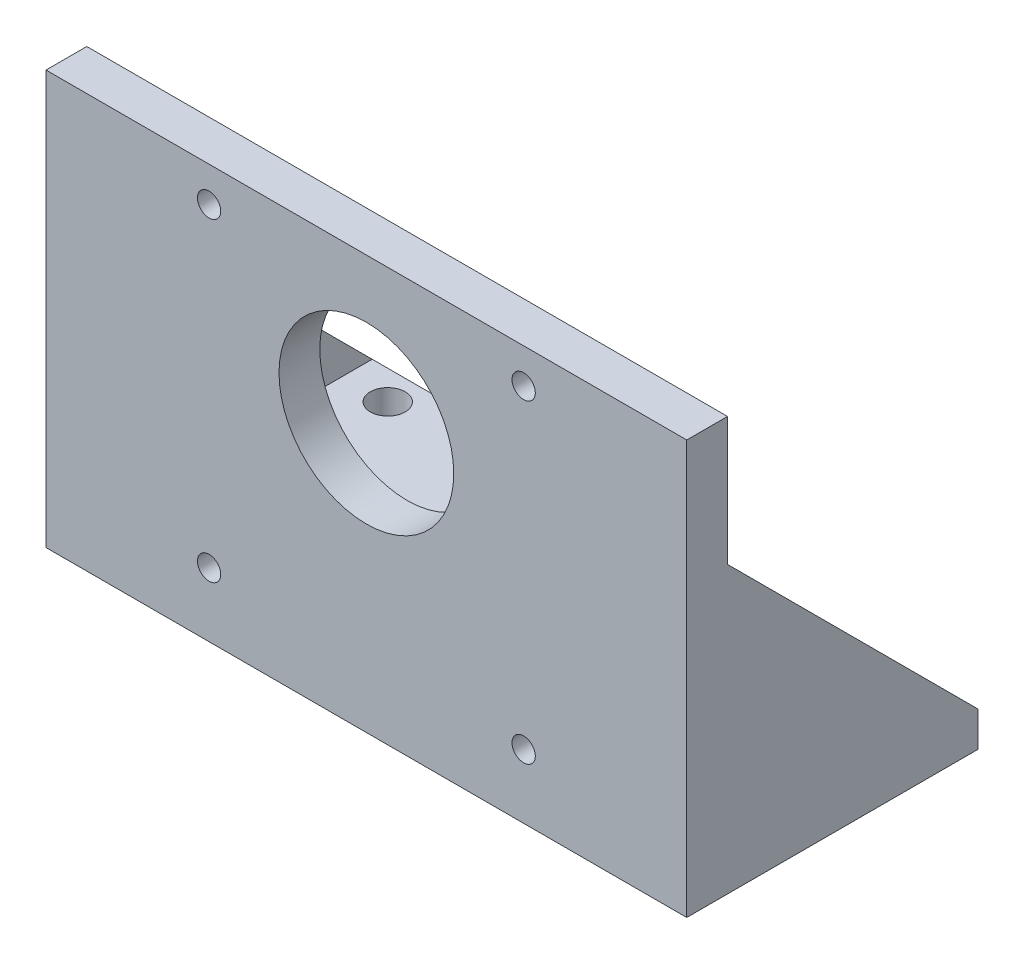
from build123d import *

# Parameters (mm, degrees)
SKETCH1_W           = 110
SKETCH1_H           = 50
SKETCH1_R           = 17.5
BOSS_EXTRUDE1_DEPTH = 6
SKETCH2_W           = 110
SKETCH2_H           = 7
BOSS_EXTRUDE2_DEPTH = 65
BOSS_EXTRUDE3_DEPTH = 6
BOSS_EXTRUDE4_DEPTH = 6
CUT_EXTRUDE1_REACH  = 52
SKETCH5_R           = 15
SKETCH6_R           = 3
CUT_EXTRUDE2_DEPTH  = 7
SKETCH7_R           = 2
CUT_EXTRUDE3_DEPTH  = 51


with BuildPart() as part:
    # Sketch1 → Boss-Extrude1 (new body)
    with BuildSketch(Plane(origin=(0, 0, 0), x_dir=(1, 0, 0), z_dir=(0, 1, 0))):
        Rectangle(SKETCH1_W, SKETCH1_H)
        Circle(SKETCH1_R, mode=Mode.SUBTRACT)
    extrude(amount=BOSS_EXTRUDE1_DEPTH)

    # Sketch2 → Boss-Extrude2 (add)
    with BuildSketch(Plane(origin=(0, 6, 0), x_dir=(1, 0, 0), z_dir=(0, 1, 0))):
        with Locations((0, -21.5)):
            Rectangle(SKETCH2_W, SKETCH2_H)
    extrude(amount=BOSS_EXTRUDE2_DEPTH)

    # Sketch3 → Boss-Extrude3 (add)
    with BuildSketch(Plane(origin=(55, 0, 0), x_dir=(0, 0, -1), z_dir=(1, 0, 0))):
        Polygon((-18, 6), (25, 6), (-18, 49), align=None)
    extrude(amount=-BOSS_EXTRUDE3_DEPTH)

    # Sketch4 → Boss-Extrude4 (add)
    with BuildSketch(Plane.ZY.offset(55)):
        Polygon((-25, 6), (18, 6), (18, 49), align=None)
    extrude(amount=-BOSS_EXTRUDE4_DEPTH)

    # Sketch5 → Cut-Extrude1 (cut, up to next)
    with BuildSketch(Plane.XY.offset(25), mode=Mode.PRIVATE) as cut_extrude1_sk1:
        with Locations((0, 46)):
            Circle(SKETCH5_R)
    cut_extrude1_tool1 = extrude(cut_extrude1_sk1.sketch, amount=-CUT_EXTRUDE1_REACH, mode=Mode.PRIVATE) & part.part
    add(cut_extrude1_tool1.solids().sort_by_distance((0, 46, 25))[0], mode=Mode.SUBTRACT)

    # Sketch6 → Cut-Extrude2 (cut, through all)
    with BuildSketch(Plane(origin=(0, 6, 0), x_dir=(1, 0, 0), z_dir=(0, 1, 0))):
        with Locations((-41.329699244, 20)):
            Circle(SKETCH6_R)
        with Locations((-41.329699244, -13)):
            Circle(SKETCH6_R)
        with Locations((41.329699244, -13)):
            Circle(SKETCH6_R)
        with Locations((41.329699244, 20)):
            Circle(SKETCH6_R)
    extrude(amount=-CUT_EXTRUDE2_DEPTH, mode=Mode.SUBTRACT)

    # Sketch7 → Cut-Extrude3 (cut, through all)
    with BuildSketch(Plane.XY.offset(25)):
        with Locations((-27, 65)):
            Circle(SKETCH7_R)
        with Locations((27, 65)):
            Circle(SKETCH7_R)
        with Locations((-27, 11)):
            Circle(SKETCH7_R)
        with Locations((27, 11)):
            Circle(SKETCH7_R)
    extrude(amount=-CUT_EXTRUDE3_DEPTH, mode=Mode.SUBTRACT)


solid = part.part
